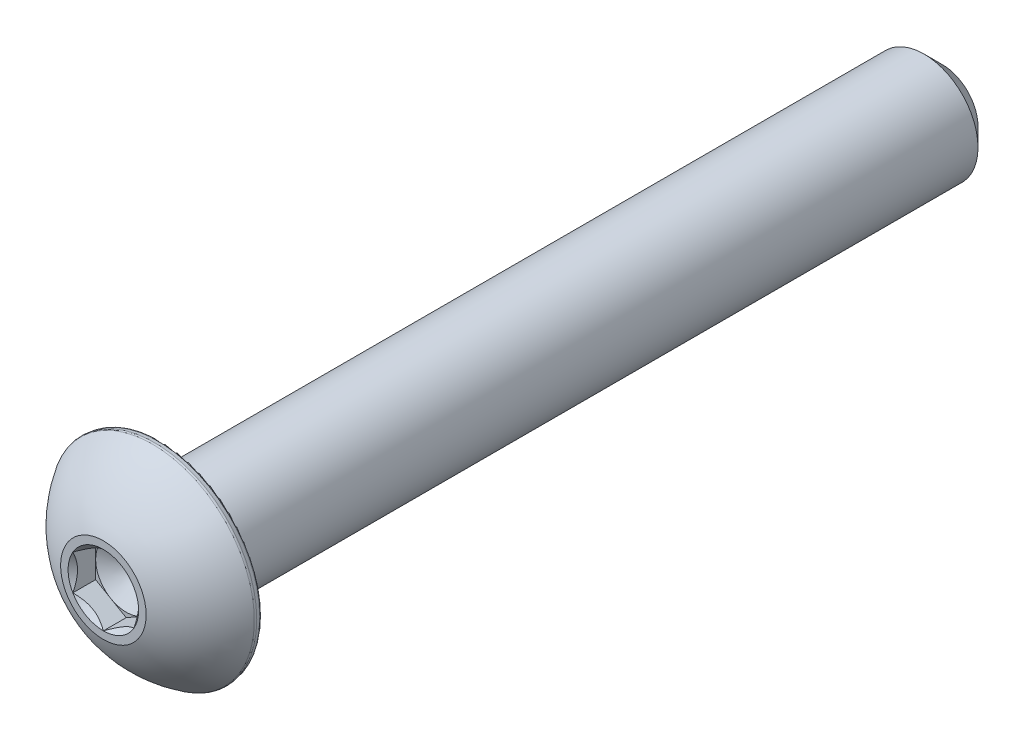
from build123d import *

# Parameters (mm, degrees)
CUT_EXTRUDE1_START = 12.88542
CUT_EXTRUDE1_DEPTH = 1.74168
SKETCH4_R          = 1.14567944
CUT_EXTRUDE2_DEPTH = 0.74168
CUT_EXTRUDE2_DRAFT = -45
FILLET1_R          = 0.09271


with BuildPart() as part:
    # Sketch2 → Revolve1 (revolve)
    with BuildSketch(Plane(origin=(0, 0, 0), x_dir=(0, 0, -1), z_dir=(1, 0, 0))):
        with BuildLine():
            Line((-13.6271, 0.9921875), (-13.6271, 1.3890625))
            ThreePointArc((-13.6271, 1.3890625), (-12.975897643, 2.494669105), (-11.999685714, 3.3274))
            Line((-11.999685714, 3.3274), (-11.7729, 3.28741156))
            Line((-11.7729, 3.28741156), (-11.7729, 1.7526))
            Line((-11.7729, 1.7526), (13.0317875, 1.7526))
            Line((13.0317875, 1.7526), (13.6271, 1.1572875))
            Line((13.6271, 1.1572875), (13.6271, 0))
            Line((13.6271, 0), (-12.31258028, 0))
            Line((-12.31258028, 0), (-12.88542, 0.9921875))
            Line((-12.88542, 0.9921875), (-13.6271, 0.9921875))
        make_face()
    revolve(axis=Axis((0, 0, 13.6271), (0, 0, -1)))

    # Sketch3 → Cut-Extrude1 (cut, through all)
    with BuildSketch(Plane.XY.offset(CUT_EXTRUDE1_START)):
        Polygon((0, 1.14567944), (-0.9921875, 0.57283972), (-0.9921875, -0.57283972), (0, -1.14567944), (0.9921875, -0.57283972), (0.9921875, 0.57283972), align=None)
    extrude(amount=CUT_EXTRUDE1_DEPTH, mode=Mode.SUBTRACT)


with BuildPart() as cut_extrude2_tool:
    # Sketch4 → Cut-Extrude2 (with draft: the straight prism first)
    with BuildSketch(Plane.XY.offset(13.6271)):
        Circle(SKETCH4_R)
    extrude(amount=-CUT_EXTRUDE2_DEPTH)
    # Cut-Extrude2: the draft: its side faces are tilted about the plane it starts from
    cut_extrude2_sides = [cut_extrude2_tool.faces().sort_by_distance(p)[0] for p in [
        (-1.14567944, 0, 13.25626),
    ]]
    draft(cut_extrude2_sides, Plane.XY.offset(13.6271), CUT_EXTRUDE2_DRAFT)


with BuildPart() as part_1:
    add(part.part)

    # Cut-Extrude2: cut by cut_extrude2_tool
    add(cut_extrude2_tool.part, mode=Mode.SUBTRACT)

    # Fillet1
    fillet1_edges = [part_1.edges().sort_by_distance(p)[0] for p in [
        (0, -3.28741156, 11.7729),
        (0, -3.3274, 11.999685714),
    ]]
    fillet(fillet1_edges, radius=FILLET1_R)


solid = part_1.part
